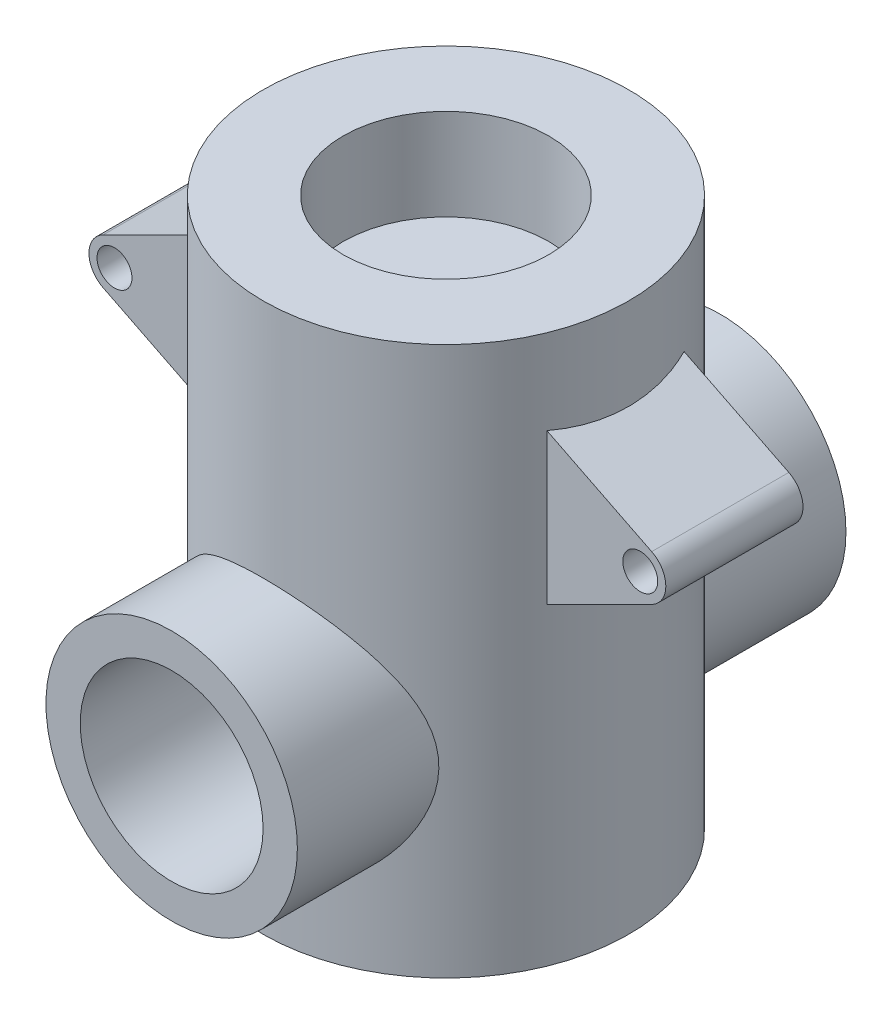
from build123d import *

# Parameters (mm, degrees)
SKETCH1_W               = 40
SKETCH1_H               = 120
SKETCH3_R               = 3.821172455
BOSS_EXTRUDE1_DEPTH     = 15
SKETCH5_R               = 27.5
BOSS_EXTRUDE2_DEPTH     = 60
SKETCH4_R               = 22.5
CUT_EXTRUDE2_DEPTH      = 20
SKETCH2_R               = 20
CUT_EXTRUDE3_DEPTH      = 61.0000001
CUT_EXTRUDE3_DEPTH_BACK = 61.0000001


with BuildPart() as part:
    # Sketch1 → Base-Revolve (revolve)
    with BuildSketch(Plane.XY):
        with Locations((20, -50)):
            Rectangle(SKETCH1_W, SKETCH1_H)
    revolve(axis=Axis((0, 300, 0), (0, -1, 0)))

    # Sketch3 → Boss-Extrude1 (add, symmetric)
    with BuildSketch(Plane.XY):
        with BuildLine():
            Line((30, -5), (60, -20))
            ThreePointArc((60, -20), (63.090169944, -25), (60, -30))
            Line((60, -30), (30, -45))
            Line((30, -45), (30, -5))
        make_face()
        with Locations((57.5, -25)):
            Circle(SKETCH3_R, mode=Mode.SUBTRACT)
    boss_extrude1 = extrude(amount=BOSS_EXTRUDE1_DEPTH, both=True)

    # Mirror1: Boss-Extrude1 across plane
    add(boss_extrude1.mirror(Plane(origin=(0, 0, 0), x_dir=(0, 0, 1), z_dir=(1, 0, 0))))

    # Sketch5 → Boss-Extrude2 (add, symmetric)
    with BuildSketch(Plane.XY):
        with Locations((0, -70)):
            Circle(SKETCH5_R)
    extrude(amount=BOSS_EXTRUDE2_DEPTH, both=True)

    # Sketch4 → Cut-Extrude2 (cut)
    with BuildSketch(Plane(origin=(0, 10, 0), x_dir=(-1, 0, 0), z_dir=(0, 1, 0))):
        Circle(SKETCH4_R)
    extrude(amount=-CUT_EXTRUDE2_DEPTH, mode=Mode.SUBTRACT)

    # Sketch2 → Cut-Extrude3 (cut, two sides)
    with BuildSketch(Plane.XY) as cut_extrude3_sk:
        with Locations((0, -70)):
            Circle(SKETCH2_R)
    extrude(amount=CUT_EXTRUDE3_DEPTH, mode=Mode.SUBTRACT)
    extrude(cut_extrude3_sk.sketch, amount=-CUT_EXTRUDE3_DEPTH_BACK, mode=Mode.SUBTRACT)


solid = part.part
